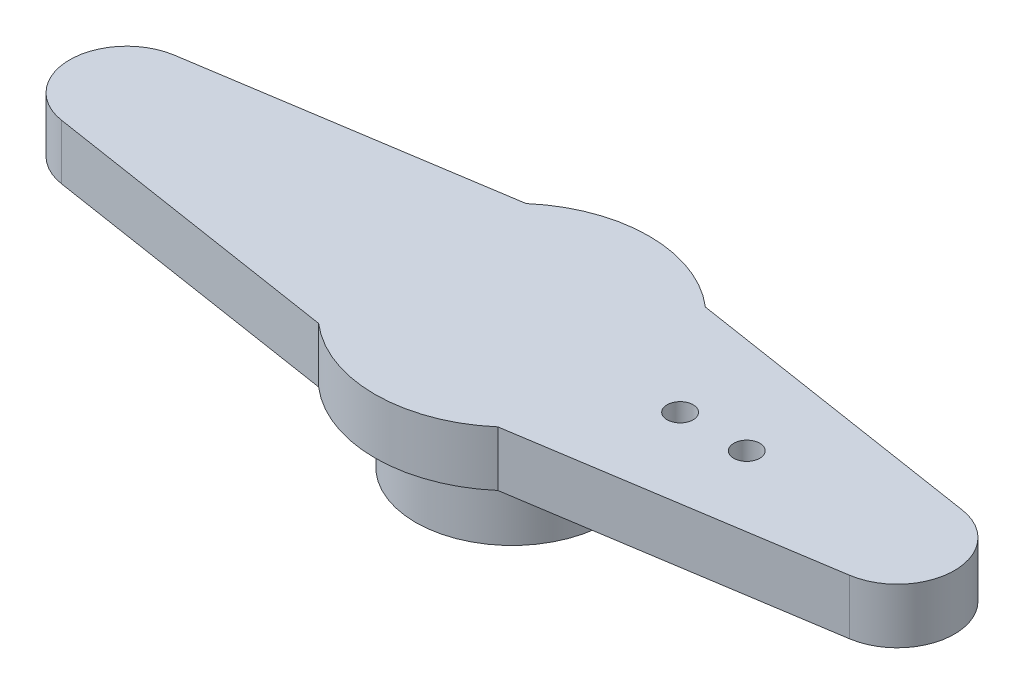
from build123d import *

# Parameters (mm, degrees)
BOSS_EXTRUDE1_DEPTH = 2.413
SKETCH2_R           = 4.22275
SKETCH2_R_2         = 2.8829
BOSS_EXTRUDE2_DEPTH = 3.3401
CUT_EXTRUDE1_REACH  = 7.753
SKETCH3_R           = 0.5715


with BuildPart() as part:
    # Sketch1 → Boss-Extrude1 (new body)
    with BuildSketch(Plane(origin=(0, 0, 0), x_dir=(1, 0, 0), z_dir=(0, 1, 0))):
        with BuildLine():
            Line((3.926025834, 4.5466), (17.264827457, 2.47015))
            ThreePointArc((17.264827457, 2.47015), (19.3802, 0), (17.264827457, -2.47015))
            Line((17.264827457, -2.47015), (3.926025834, -4.5466))
            ThreePointArc((3.926025834, -4.5466), (0, -6.0071), (-3.926025834, -4.5466))
            Line((-3.926025834, -4.5466), (-17.264827457, -2.47015))
            ThreePointArc((-17.264827457, -2.47015), (-19.3802, 0), (-17.264827457, 2.47015))
            Line((-17.264827457, 2.47015), (-3.926025834, 4.5466))
            ThreePointArc((-3.926025834, 4.5466), (0, 6.0071), (3.926025834, 4.5466))
        make_face()
    extrude(amount=BOSS_EXTRUDE1_DEPTH)

    # Sketch2 → Boss-Extrude2 (add)
    with BuildSketch(Plane.XZ):
        Circle(SKETCH2_R)
        Circle(SKETCH2_R_2, mode=Mode.SUBTRACT)
    extrude(amount=BOSS_EXTRUDE2_DEPTH)

    # Sketch3 → Cut-Extrude1 (cut, up to next)
    with BuildSketch(Plane(origin=(0, 2.413, 0), x_dir=(1, 0, 0), z_dir=(0, 1, 0)), mode=Mode.PRIVATE) as cut_extrude1_sk1:
        with Locations((7.366, 0)):
            Circle(SKETCH3_R)
    cut_extrude1_tool1 = extrude(cut_extrude1_sk1.sketch, amount=-CUT_EXTRUDE1_REACH, mode=Mode.PRIVATE) & part.part
    add(cut_extrude1_tool1.solids().sort_by_distance((7.366, 2.413, 0))[0], mode=Mode.SUBTRACT)
    # Sketch3 → Cut-Extrude1 (cut, up to next)
    with BuildSketch(Plane(origin=(0, 2.413, 0), x_dir=(1, 0, 0), z_dir=(0, 1, 0)), mode=Mode.PRIVATE) as cut_extrude1_sk2:
        with Locations((10.287, 0)):
            Circle(SKETCH3_R)
    cut_extrude1_tool2 = extrude(cut_extrude1_sk2.sketch, amount=-CUT_EXTRUDE1_REACH, mode=Mode.PRIVATE) & part.part
    add(cut_extrude1_tool2.solids().sort_by_distance((10.287, 2.413, 0))[0], mode=Mode.SUBTRACT)


solid = part.part
